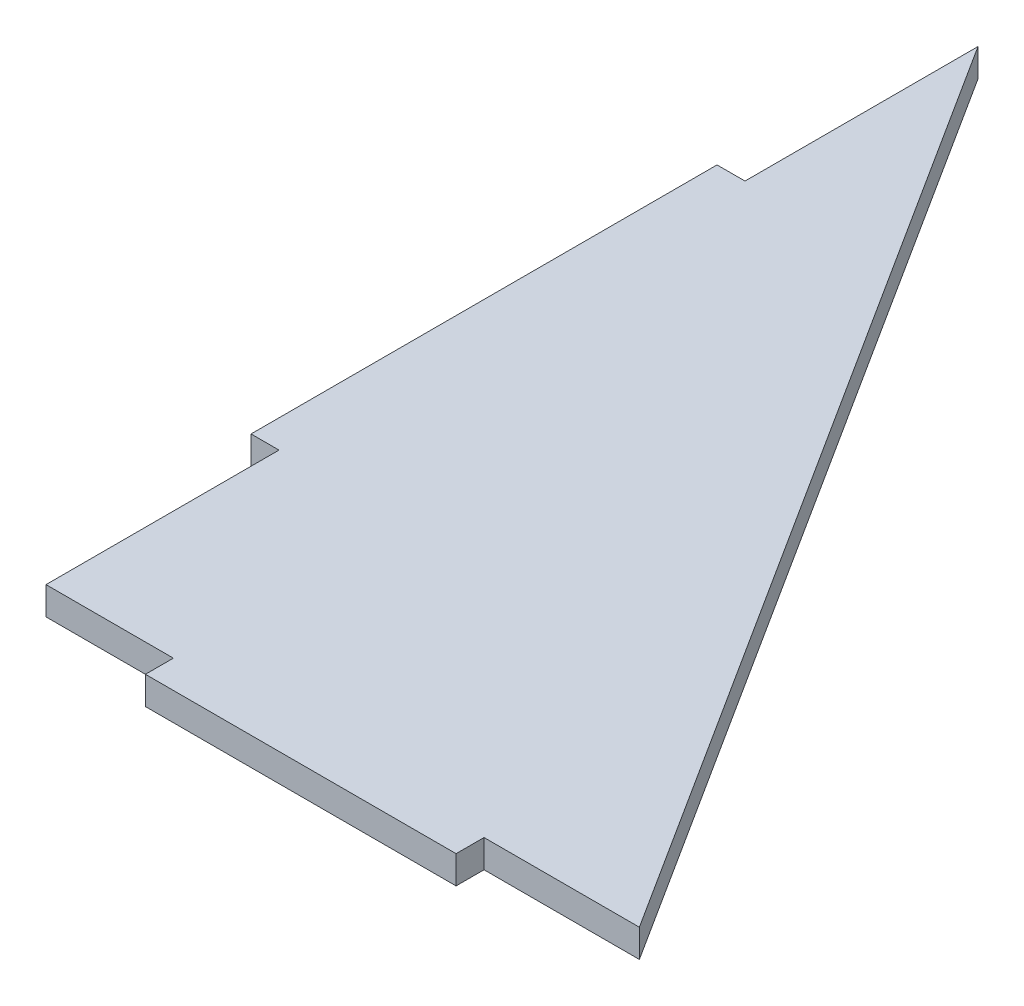
from build123d import *

# Parameters (mm, degrees)
SKETCH1_W           = 4.5
SKETCH1_H           = 75
SKETCH1_W_2         = 50
SKETCH1_H_2         = 4.5
BOSS_EXTRUDE1_DEPTH = 4.5


with BuildPart() as part:
    # Sketch1 → Boss-Extrude1 (new body)
    with BuildSketch(Plane(origin=(0, 0, 0), x_dir=(1, 0, 0), z_dir=(0, 1, 0))):
        with Locations((-2.25, 75)):
            Rectangle(SKETCH1_W, SKETCH1_H)
        Polygon((0, 37.5), (0, 0), (20.5, 0), (20.5, 4.5), (70.5, 4.5), (70.5, 0), (95.5, 0), (0, 150), (0, 112.5), (4.5, 112.5), (4.5, 37.5), align=None)
        with Locations((45.5, -2.25)):
            Rectangle(SKETCH1_W_2, SKETCH1_H_2)
        with Locations((45.5, 2.25)):
            Rectangle(SKETCH1_W_2, SKETCH1_H_2)
        with Locations((2.25, 75)):
            Rectangle(SKETCH1_W, SKETCH1_H)
    extrude(amount=BOSS_EXTRUDE1_DEPTH)


solid = part.part
